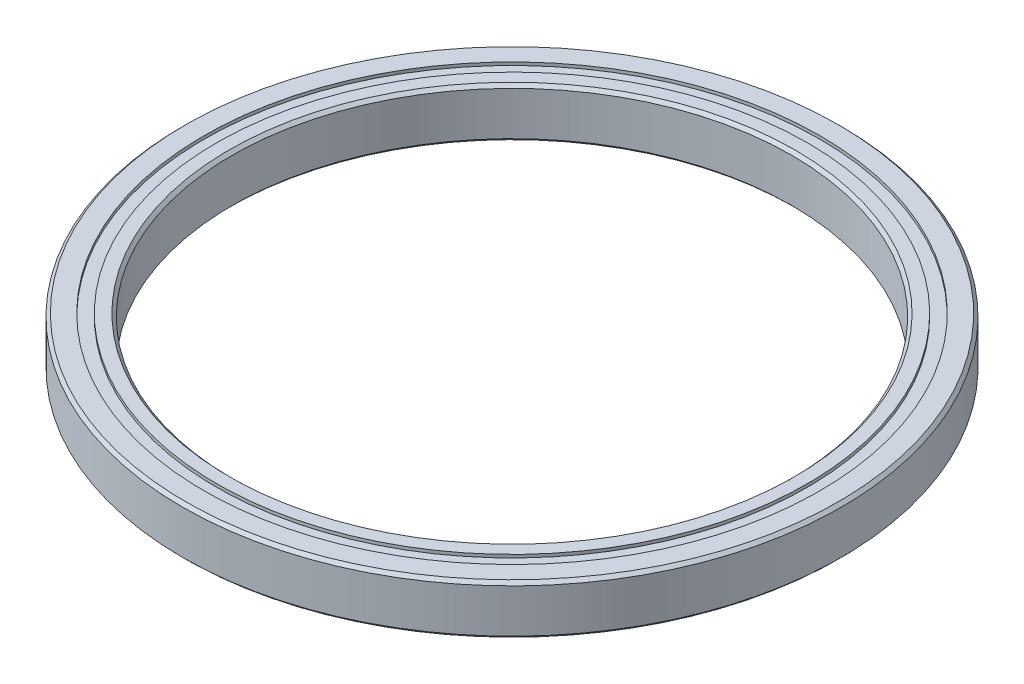
from build123d import *


with BuildPart() as part:
    # 草图1 → 旋转1 (revolve)
    with BuildSketch(Plane.XY):
        Polygon((-45.5, 0), (-47.5, 0), (-47.5, 0.5), (-49.5, 0.5), (-49.5, 0), (-52.5, 0), (-53, 0.5), (-53, 7.5), (-52.5, 8), (-49.5, 8), (-49.5, 7.5), (-47.5, 7.5), (-47.5, 8), (-45.5, 8), (-45, 7.5), (-45, 0.5), align=None)
    revolve(axis=Axis((0, 0, 0), (0, 1, 0)))


solid = part.part
